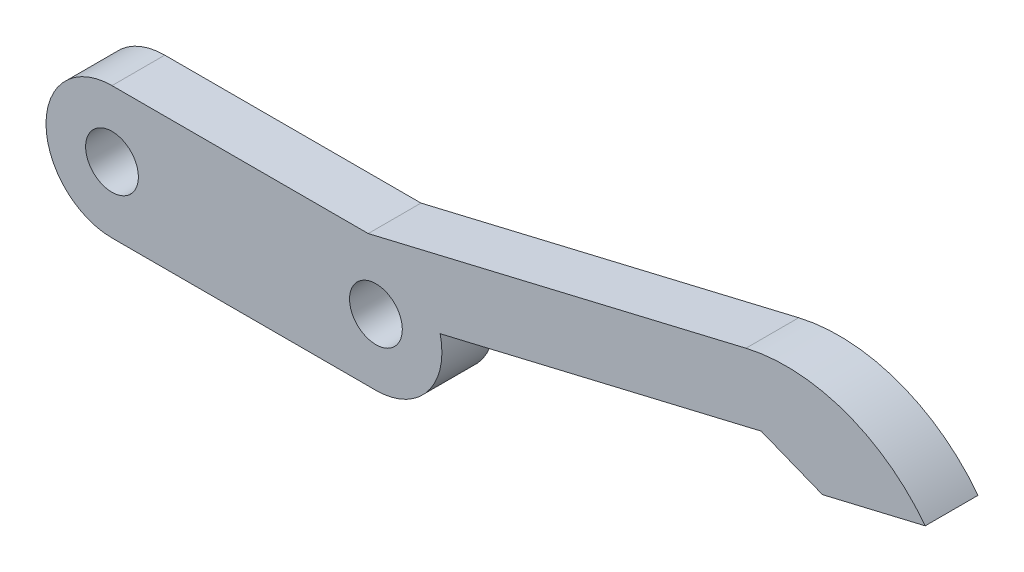
from build123d import *

# Parameters (mm, degrees)
EXTRUDE_1_DEPTH     = 4
SKETCH_2_R          = 2
CUT_EXTRUDE_1_DEPTH = 4
EXTRUDE_3_DEPTH     = 4


with BuildPart() as part:
    # 草图1 → 凸台-拉伸1 (new body)
    with BuildSketch(Plane.XY):
        with BuildLine():
            Line((-10, 5), (10, 5))
            ThreePointArc((10, 5), (15, 0), (10, -5))
            Line((10, -5), (-10, -5))
            ThreePointArc((-10, -5), (-15, 0), (-10, 5))
        make_face()
    extrude(amount=EXTRUDE_1_DEPTH)

    # 草图2 → 切除-拉伸1 (cut)
    with BuildSketch(Plane.XY.offset(4)):
        with Locations((-10, 0)):
            Circle(SKETCH_2_R)
        with Locations((10, 0)):
            Circle(SKETCH_2_R)
    extrude(amount=-CUT_EXTRUDE_1_DEPTH, mode=Mode.SUBTRACT)

    # 草图3 → 凸台-拉伸3 (add)
    with BuildSketch(Plane.XY.offset(4)):
        with BuildLine():
            Line((11.946050783, 0.461396089), (39.19076174, 6.920941341))
            Line((39.19076174, 6.920941341), (43.837655244, 5.075303033))
            Line((43.837655244, 5.075303033), (51.621858375, 6.920887391))
            ThreePointArc((51.621858375, 6.920887391), (45.551115726, 11.368196193), (38.037271516, 11.786068297))
            Line((38.037271516, 11.786068297), (8.846509777, 4.865126957))
            Line((8.846509777, 4.865126957), (9.538603911, 1.946050783))
            ThreePointArc((9.538603911, 1.946050783), (11.049809401, 1.702322009), (11.946050783, 0.461396089))
        make_face()
    extrude(amount=-EXTRUDE_3_DEPTH)


solid = part.part
